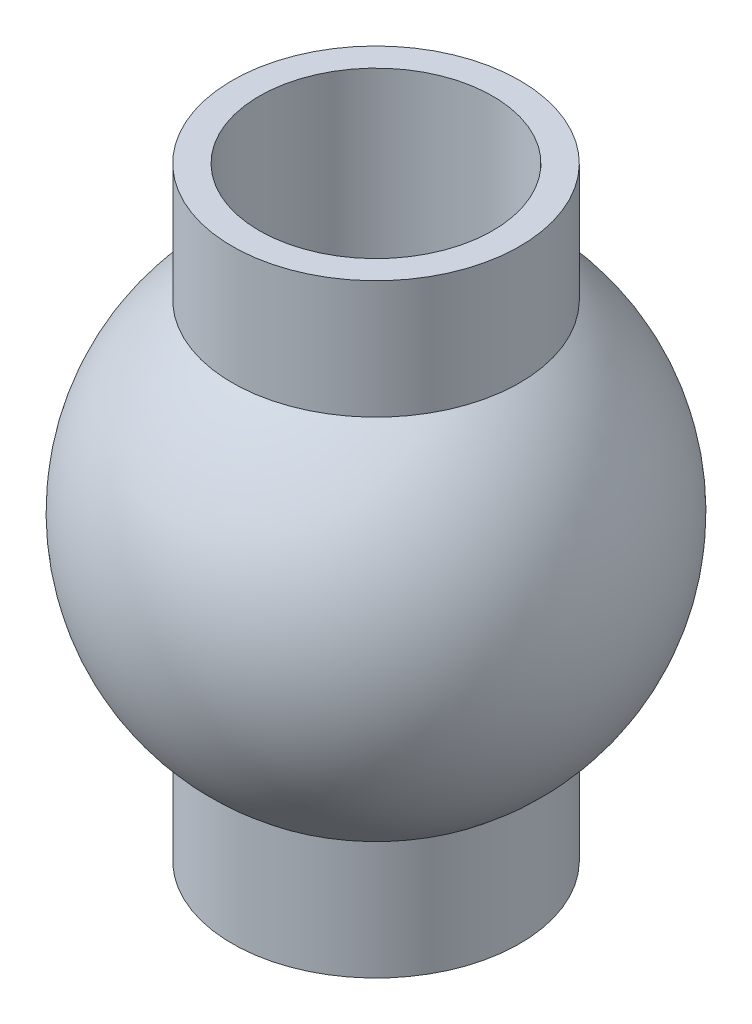
from build123d import *

# Parameters (mm, degrees)
SKETCH3_R          = 2.5
CUT_EXTRUDE1_DEPTH = 13.94067


with BuildPart() as part:
    # Sketch2 → Revolve1 (revolve)
    with BuildSketch(Plane.XY):
        with BuildLine():
            Line((0, 12.94067), (2.236893325, 12.94067))
            Line((2.236893325, 12.94067), (3.080570164, 12.94067))
            Line((3.080570164, 12.94067), (3.080570164, 10.408619838))
            ThreePointArc((3.080570164, 10.408619838), (5, 6.470335), (3.080570164, 2.532050162))
            Line((3.080570164, 2.532050162), (3.080570164, 0))
            Line((3.080570164, 0), (2.236893325, 0))
            Line((2.236893325, 0), (0, 0))
            Line((0, 0), (0, 12.94067))
        make_face()
    revolve(axis=Axis((0, 0, 0), (0, 1, 0)))

    # Sketch3 → Cut-Extrude1 (cut, through all)
    with BuildSketch(Plane(origin=(0, 12.94067, 0), x_dir=(1, 0, 0), z_dir=(0, 1, 0))):
        Circle(SKETCH3_R)
    extrude(amount=-CUT_EXTRUDE1_DEPTH, mode=Mode.SUBTRACT)


solid = part.part
